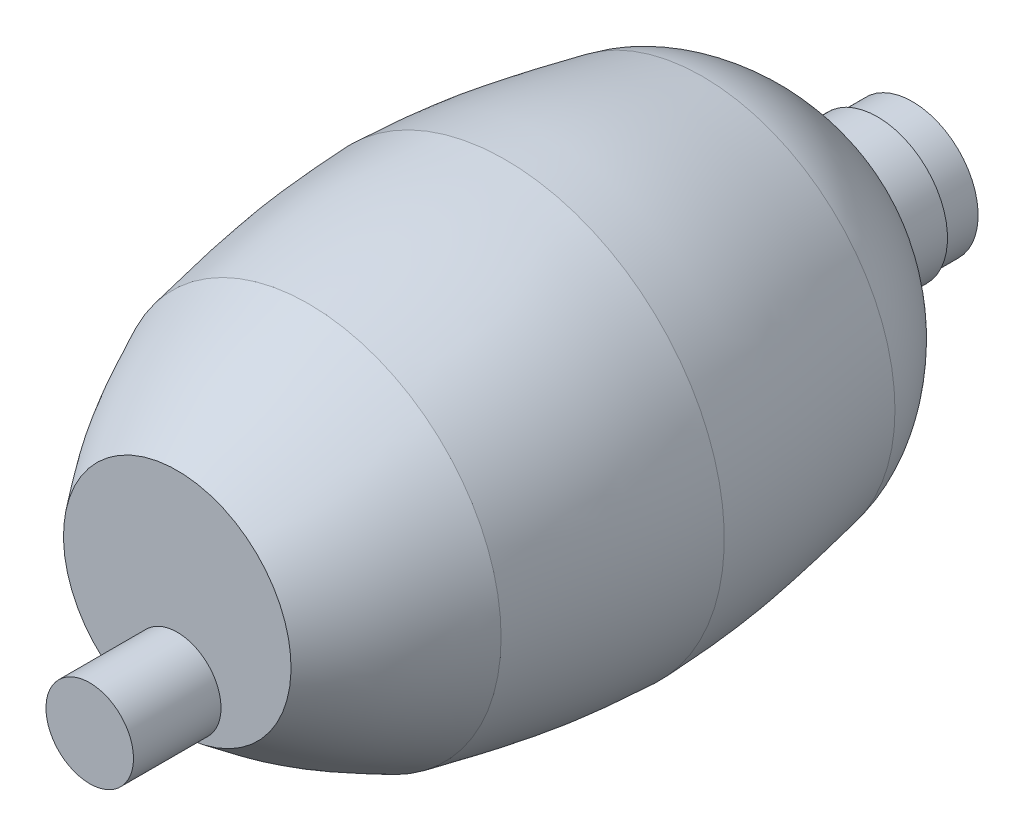
from build123d import *

# Parameters (mm, degrees)
SKETCH4_R            = 12.7
BAG_ATTACHMENT_DEPTH = 25.4
SCALE1_SCALE         = 0.625


with BuildPart() as part:
    # Sketch1 → body (revolve)
    with BuildSketch(Plane(origin=(0, 0, 0), x_dir=(1, 0, 0), z_dir=(0, 1, 0))):
        with BuildLine():
            Line((0, 95.25), (0, -95.25))
            Line((0, -95.25), (33.02, -95.25))
            add(Edge.make_bspline(
                [(55.88, -57.15), (52.333253403, -64.649759535), (45.965562244, -78.114536673), (36.994334659, -89.98935048), (33.02, -95.25)],
                knots=[0, 0, 0, 0, 0.556990989, 1, 1, 1, 1], degree=3))
            add(Edge.make_bspline(
                [(55.88, -57.15), (58.418345497, -44.49907482), (62.211374207, -25.594901819), (63.179693062, -6.361990172), (63.5, 0)],
                knots=[0, 0, 0, 0, 0.669213363, 1, 1, 1, 1], degree=3))
            add(Edge.make_bspline(
                [(55.88, 57.15), (58.418345497, 44.49907482), (62.211374207, 25.594901819), (63.179693062, 6.361990172), (63.5, 0)],
                knots=[0, 0, 0, 0, 0.669213363, 1, 1, 1, 1], degree=3))
            add(Edge.make_bspline(
                [(20.32, 95.25), (27.263983104, 91.241807371), (42.563906598, 82.410414831), (54.075514966, 66.14341921), (55.88, 57.15)],
                knots=[0, 0, 0, 0, 0.453857374, 1, 1, 1, 1], degree=3))
            Line((20.32, 95.25), (20.32, 107.95))
            Line((20.32, 107.95), (19.05, 107.95))
            Line((19.05, 107.95), (19.05, 118.11))
            Line((19.05, 118.11), (0, 118.11))
            Line((0, 118.11), (0, 107.95))
            Line((0, 107.95), (0, 95.25))
        make_face()
    revolve(axis=Axis((0, 0, -95.25), (0, 0, 1)))

    # Sketch4 → bag_attachment (add)
    with BuildSketch(Plane.XY.offset(95.25)):
        with Locations((0, -20.32)):
            Circle(SKETCH4_R)
    extrude(amount=BAG_ATTACHMENT_DEPTH)


with BuildPart() as part_1:
    # Scale1: scaled about (-8.591e-06, -0.141365899, 0.01703512)
    add(part.part.scale(SCALE1_SCALE).moved(Location((-3.222e-06, -0.053012212, 0.00638817))))


solid = part_1.part
